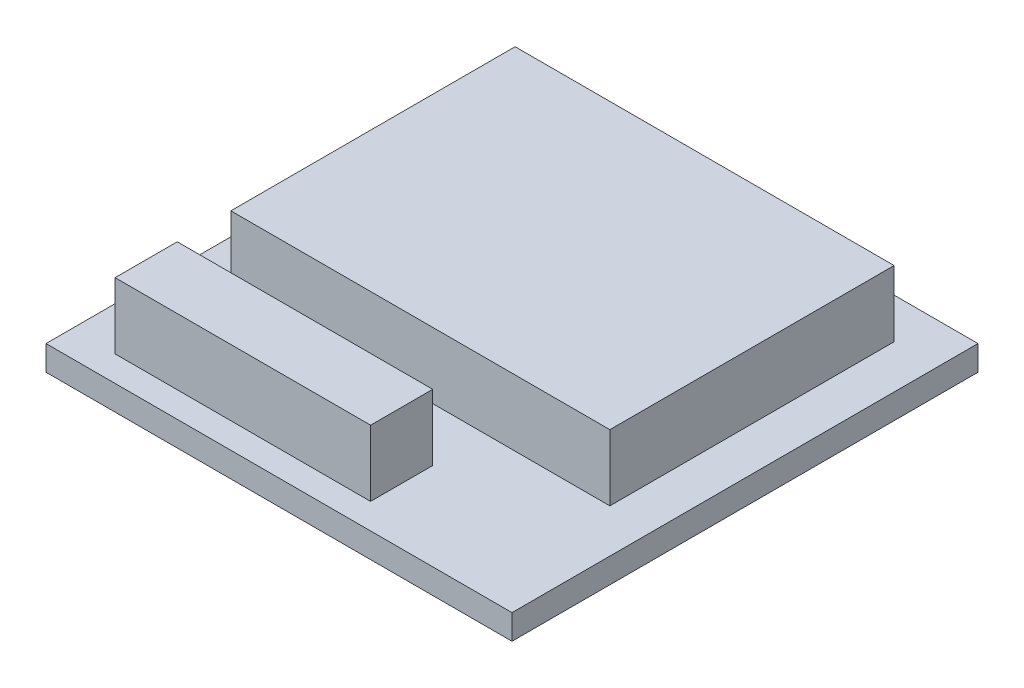
from build123d import *

# Parameters (mm, degrees)
SKETCH1_W             = 15.24
SKETCH1_H             = 15.24
BOSS_EXTRUDE1_DEPTH   = 0.8128
SKETCH2_W             = 12.3952
SKETCH2_H             = 9.2964
BOSS_EXTRUDE2_DEPTH   = 2.159
SKETCH2_W_2           = 8.356011574
SKETCH2_H_2           = 2.032
BOSS_EXTRUDE2_2_DEPTH = 2.159


with BuildPart() as part:
    # Sketch1 → Boss-Extrude1 (new body)
    with BuildSketch(Plane(origin=(0, 0, 0), x_dir=(1, 0, 0), z_dir=(0, 1, 0))):
        Rectangle(SKETCH1_W, SKETCH1_H)
    extrude(amount=BOSS_EXTRUDE1_DEPTH)


with BuildPart() as body_2:
    # Sketch2 → Boss-Extrude2 (new body)
    with BuildSketch(Plane(origin=(0, 0.8128, 0), x_dir=(-1, 0, 0), z_dir=(0, 1, 0))):
        with Locations((0, -1.651)):
            Rectangle(SKETCH2_W, SKETCH2_H)
    extrude(amount=BOSS_EXTRUDE2_DEPTH)


with BuildPart() as body_3:
    # Sketch2 → Boss-Extrude2 2 (new body)
    with BuildSketch(Plane(origin=(0, 0.8128, 0), x_dir=(-1, 0, 0), z_dir=(0, 1, 0))):
        with Locations((2.019594213, 5.766936548)):
            Rectangle(SKETCH2_W_2, SKETCH2_H_2)
    extrude(amount=BOSS_EXTRUDE2_2_DEPTH)


solid = Compound([part.part, body_2.part, body_3.part])
